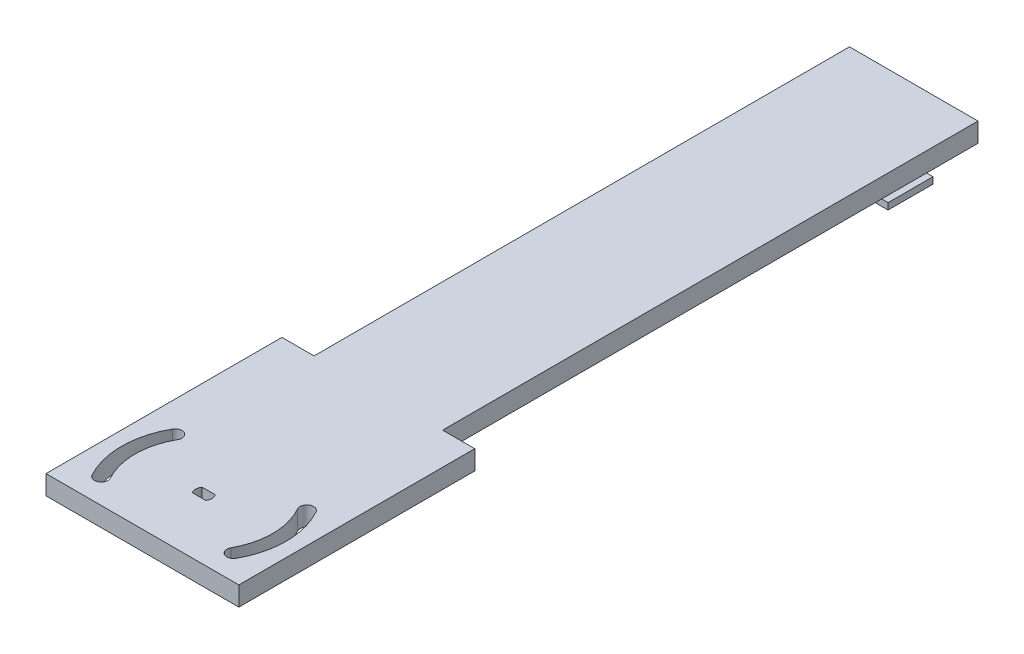
from build123d import *

# Parameters (mm, degrees)
SKETCH1_W                = 40
SKETCH1_H                = 240
BOSS_EXTRUDE1_DEPTH      = 6
SKETCH3_W                = 73.413063841
SKETCH3_H                = 6
BOSS_EXTRUDE2_DEPTH      = 10
BOSS_EXTRUDE2_DEPTH_BACK = 50
SKETCH4_W                = 28
SKETCH4_H                = 14
BOSS_EXTRUDE3_DEPTH      = 8
SKETCH5_W                = 14
SKETCH5_H                = 2
BOSS_EXTRUDE4_DEPTH      = 2
BOSS_EXTRUDE4_DEPTH_BACK = 30
CUT_EXTRUDE1_DEPTH       = 10


with BuildPart() as part:
    # Sketch1 → Boss-Extrude1 (new body)
    with BuildSketch(Plane(origin=(0, 0, 0), x_dir=(1, 0, 0), z_dir=(0, 1, 0))):
        Rectangle(SKETCH1_W, SKETCH1_H)
    extrude(amount=BOSS_EXTRUDE1_DEPTH)

    # Sketch3 → Boss-Extrude2 (add, two sides)
    with BuildSketch(Plane(origin=(20, 0, 0), x_dir=(0, 0, -1), z_dir=(1, 0, 0))) as boss_extrude2_sk:
        with Locations((-83.29346808, 3)):
            Rectangle(SKETCH3_W, SKETCH3_H)
    extrude(amount=BOSS_EXTRUDE2_DEPTH)
    extrude(boss_extrude2_sk.sketch, amount=-BOSS_EXTRUDE2_DEPTH_BACK)

    # Sketch4 → Boss-Extrude3 (add)
    with BuildSketch(Plane.XZ):
        with Locations((0, -103)):
            Rectangle(SKETCH4_W, SKETCH4_H)
    extrude(amount=BOSS_EXTRUDE3_DEPTH)

    # Sketch5 → Boss-Extrude4 (add, two sides)
    with BuildSketch(Plane(origin=(14, 0, 0), x_dir=(0, 0, -1), z_dir=(1, 0, 0))) as boss_extrude4_sk:
        with Locations((103, -7)):
            Rectangle(SKETCH5_W, SKETCH5_H)
    extrude(amount=BOSS_EXTRUDE4_DEPTH)
    extrude(boss_extrude4_sk.sketch, amount=-BOSS_EXTRUDE4_DEPTH_BACK)

    # Sketch2 → Cut-Extrude1 (cut)
    with BuildSketch(Plane.XZ):
        with BuildLine():
            Line((-2.05, 99.374369573), (2.05, 99.374369573))
            ThreePointArc((2.05, 99.374369573), (2.540177159, 100.874369573), (2.05, 102.374369573))
            Line((2.05, 102.374369573), (-2.05, 102.374369573))
            ThreePointArc((-2.05, 102.374369573), (-2.540177159, 100.874369573), (-2.05, 99.374369573))
        make_face()
        with BuildLine():
            ThreePointArc((-21.42, 100.874369573), (-20.718261003, 95.436533515), (-18.659023249, 90.354994526))
            ThreePointArc((-18.659023249, 90.354994526), (-19.457027975, 87.494367242), (-22.317655259, 88.292371968))
            ThreePointArc((-22.317655259, 88.292371968), (-24.780665122, 94.37029115), (-25.62, 100.874369573))
            ThreePointArc((-25.62, 100.874369573), (-24.814500332, 107.248141867), (-22.44865158, 113.221127942))
            ThreePointArc((-22.44865158, 113.221127942), (-19.596568798, 114.049151976), (-18.768544764, 111.197069193))
            ThreePointArc((-18.768544764, 111.197069193), (-20.746549458, 106.203261163), (-21.42, 100.874369573))
        make_face()
        with BuildLine():
            ThreePointArc((25.62, 100.874369573), (24.780665122, 94.37029115), (22.317655259, 88.292371968))
            ThreePointArc((22.317655259, 88.292371968), (19.457027975, 87.494367242), (18.659023249, 90.354994526))
            ThreePointArc((18.659023249, 90.354994526), (20.718261003, 95.436533515), (21.42, 100.874369573))
            ThreePointArc((21.42, 100.874369573), (20.746549458, 106.203261163), (18.768544764, 111.197069193))
            ThreePointArc((18.768544764, 111.197069193), (19.596568798, 114.049151976), (22.44865158, 113.221127942))
            ThreePointArc((22.44865158, 113.221127942), (24.814500332, 107.248141867), (25.62, 100.874369573))
        make_face()
    extrude(amount=-CUT_EXTRUDE1_DEPTH, mode=Mode.SUBTRACT)


solid = part.part
